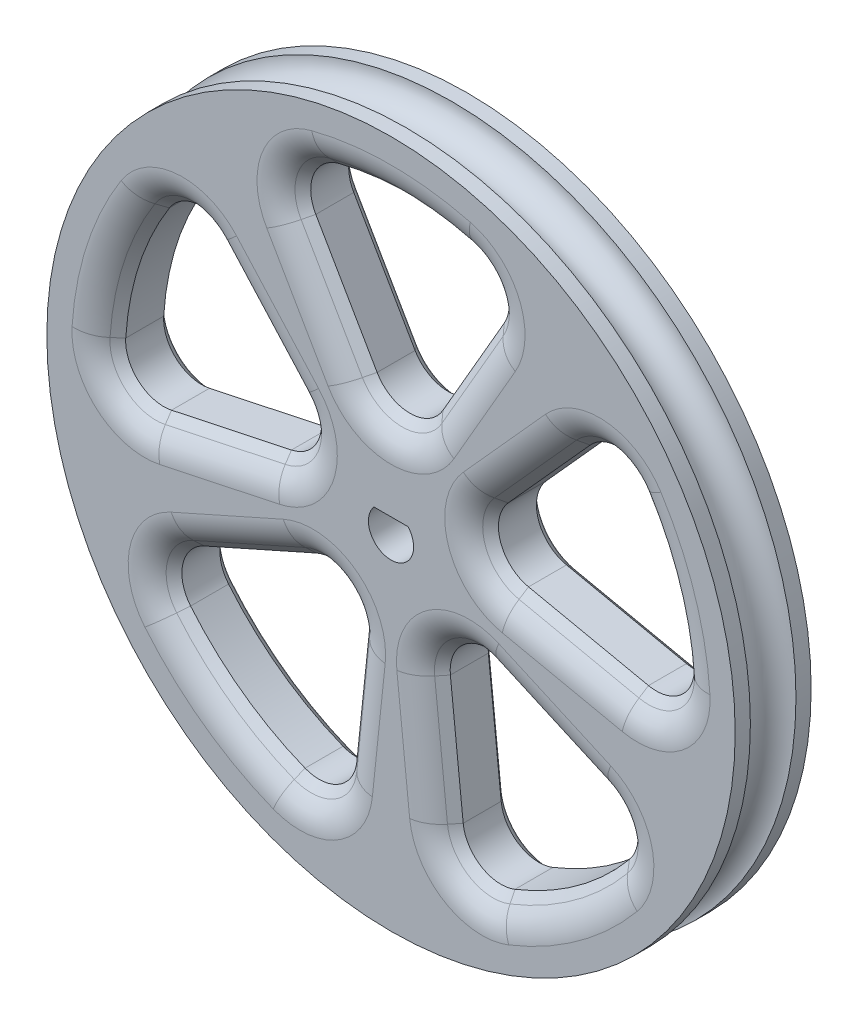
from build123d import *

# Parameters (mm, degrees)
SKETCH1_R                    = 23.01875
BOSS_EXTRUDE1_DEPTH          = 5.08
CUT_EXTRUDE3_DEPTH           = 5.08
FILLET3_R                    = 2.54
CHAMFER2_SIZE                = 1.27
CIRPATTERN3_COUNT            = 5
FILLET3_OF_CIRPATTERN3_R     = 2.54
CHAMFER2_OF_CIRPATTERN3_SIZE = 1.27
CUT_EXTRUDE4_DEPTH           = 5.08
FILLET4_R                    = 2.54


with BuildPart() as part:
    # Sketch1 → Boss-Extrude1 (new body)
    with BuildSketch(Plane.XY):
        Circle(SKETCH1_R)
    extrude(amount=BOSS_EXTRUDE1_DEPTH)

    # Sketch2 → Cut-Extrude3 (cut)
    with BuildSketch(Plane.XY.offset(5.08)):
        with BuildLine():
            Line((0, 3.81), (7.827476944, 17.367587762))
            ThreePointArc((7.827476944, 17.367587762), (0, 19.05), (-7.827476944, 17.367587762))
            Line((-7.827476944, 17.367587762), (0, 3.81))
        make_face()
    cut_extrude3 = extrude(amount=-CUT_EXTRUDE3_DEPTH, mode=Mode.SUBTRACT)

    # Fillet3
    fillet3_edges = [part.edges().sort_by_distance(p)[0] for p in [
        (7.827476944, 17.367587762, 2.54),
        (0, 3.81, 2.54),
        (-7.827476944, 17.367587762, 2.54),
    ]]
    fillet(fillet3_edges, radius=FILLET3_R)

    # Chamfer2
    chamfer2_edges = [part.edges().sort_by_distance(p)[0] for p in [
        (4.250057994, 11.17131638, 0),
        (4.250057994, 11.17131638, 5.08),
        (-4.250057994, 11.17131638, 5.08),
        (-4.250057994, 11.17131638, 0),
        (0, 19.05, 0),
        (0, 19.05, 5.08),
        (0, 6.35, 5.08),
        (0, 6.35, 0),
        (-6.442080419, 16.977300326, 5.08),
        (-6.442080419, 16.977300326, 0),
        (6.442080419, 16.977300326, 5.08),
        (6.442080419, 16.977300326, 0),
    ]]
    chamfer(chamfer2_edges, length=CHAMFER2_SIZE)

    # CirPattern3: Cut-Extrude3 ×5 about axis
    cirpattern3_axis = Axis((0, 0, 0), (0, 0, 1))
    for i in range(1, CIRPATTERN3_COUNT):
        add(cut_extrude3.rotate(cirpattern3_axis, i * 360 / CIRPATTERN3_COUNT), mode=Mode.SUBTRACT)

    # Fillet3 of CirPattern3
    fillet3_of_cirpattern3_edges = [part.edges().sort_by_distance(p)[0] for p in [
        (-14.098734115, 12.811252724, 2.54),
        (-3.623525327, 1.177354749, 2.54),
        (-18.936380913, -2.077493184, 2.54),
        (-16.540973826, -9.449798141, 2.54),
        (-2.239461811, -3.082354749, 2.54),
        (-3.875850084, -18.651549162, 2.54),
        (3.875850084, -18.651549162, 2.54),
        (2.239461811, -3.082354749, 2.54),
        (16.540973826, -9.449798141, 2.54),
        (18.936380913, -2.077493184, 2.54),
        (3.623525327, 1.177354749, 2.54),
        (14.098734115, 12.811252724, 2.54),
    ]]
    fillet(fillet3_of_cirpattern3_edges, radius=FILLET3_OF_CIRPATTERN3_R)

    # Chamfer2 of CirPattern3
    chamfer2_of_cirpattern3_edges = [part.edges().sort_by_distance(p)[0] for p in [
        (-9.311213092, 7.494171961, 0),
        (-9.311213092, 7.494171961, 5.08),
        (-11.937893386, -0.589918739, 5.08),
        (-11.937893386, -0.589918739, 0),
        (-18.117626635, 5.886773743, 0),
        (-18.117626635, 5.886773743, 5.08),
        (-6.039208878, 1.962257914, 5.08),
        (-6.039208878, 1.962257914, 0),
        (-18.137084433, -0.880508242, 5.08),
        (-18.137084433, -0.880508242, 0),
        (-14.155659776, 11.373056881, 5.08),
        (-14.155659776, 11.373056881, 0),
        (-10.004704161, -6.539663391, 0),
        (-10.004704161, -6.539663391, 5.08),
        (-3.127965873, -11.535906211, 5.08),
        (-3.127965873, -11.535906211, 0),
        (-11.197309056, -15.411773743, 0),
        (-11.197309056, -15.411773743, 5.08),
        (-3.732436352, -5.137257914, 5.08),
        (-3.732436352, -5.137257914, 0),
        (-4.767254217, -17.521484347, 5.08),
        (-4.767254217, -17.521484347, 0),
        (-15.190759294, -9.948364618, 5.08),
        (-15.190759294, -9.948364618, 0),
        (3.127965873, -11.535906211, 0),
        (3.127965873, -11.535906211, 5.08),
        (10.004704161, -6.539663391, 5.08),
        (10.004704161, -6.539663391, 0),
        (11.197309056, -15.411773743, 0),
        (11.197309056, -15.411773743, 5.08),
        (3.732436352, -5.137257914, 5.08),
        (3.732436352, -5.137257914, 0),
        (15.190759294, -9.948364618, 5.08),
        (15.190759294, -9.948364618, 0),
        (4.767254217, -17.521484347, 5.08),
        (4.767254217, -17.521484347, 0),
        (11.937893386, -0.589918739, 0),
        (11.937893386, -0.589918739, 5.08),
        (9.311213092, 7.494171961, 5.08),
        (9.311213092, 7.494171961, 0),
        (18.117626635, 5.886773743, 0),
        (18.117626635, 5.886773743, 5.08),
        (6.039208878, 1.962257914, 5.08),
        (6.039208878, 1.962257914, 0),
        (14.155659776, 11.373056881, 5.08),
        (14.155659776, 11.373056881, 0),
        (18.137084433, -0.880508242, 5.08),
        (18.137084433, -0.880508242, 0),
    ]]
    chamfer(chamfer2_of_cirpattern3_edges, length=CHAMFER2_OF_CIRPATTERN3_SIZE)

    # Sketch5 → Cut-Extrude4 (cut)
    with BuildSketch(Plane.XY.offset(5.08)):
        with BuildLine():
            ThreePointArc((1.141376069, 0.9906), (0, -1.5113), (-1.141376069, 0.9906))
            Line((-1.141376069, 0.9906), (1.141376069, 0.9906))
        make_face()
    extrude(amount=-CUT_EXTRUDE4_DEPTH, mode=Mode.SUBTRACT)

    # Fillet4
    fillet4_edges = [part.edges().sort_by_distance(p)[0] for p in [
        (-18.967083783, -1.84175799, 5.08),
        (-19.325468411, 6.279225326, 5.08),
        (-11.673845539, -1.832166191, 5.08),
        (-4.831367103, 1.569806331, 5.08),
        (-8.367419164, 8.343967831, 5.08),
        (-14.26213493, 12.63858564, 5.08),
        (-19.325468411, 6.279225326, 0),
        (-18.967083783, -1.84175799, 0),
        (-11.673845539, -1.832166191, 0),
        (-4.831367103, 1.569806331, 0),
        (-8.367419164, 8.343967831, 0),
        (-14.26213493, 12.63858564, 0),
        (-4.109535285, -18.607903146, 5.08),
        (-11.943796327, -16.439225326, 5.08),
        (-1.864923066, -11.66865736, 5.08),
        (-2.985949082, -4.109806331, 5.08),
        (-10.521259698, -5.37946066, 5.08),
        (-16.427251299, -9.658558614, 5.08),
        (-11.943796327, -16.439225326, 0),
        (-4.109535285, -18.607903146, 0),
        (-1.864923066, -11.66865736, 0),
        (-2.985949082, -4.109806331, 0),
        (-10.521259698, -5.37946066, 0),
        (-16.427251299, -9.658558614, 0),
        (16.427251299, -9.658558614, 5.08),
        (11.943796327, -16.439225326, 5.08),
        (10.521259698, -5.37946066, 5.08),
        (2.985949082, -4.109806331, 5.08),
        (1.864923066, -11.66865736, 5.08),
        (4.109535285, -18.607903146, 5.08),
        (11.943796327, -16.439225326, 0),
        (16.427251299, -9.658558614, 0),
        (10.521259698, -5.37946066, 0),
        (2.985949082, -4.109806331, 0),
        (1.864923066, -11.66865736, 0),
        (4.109535285, -18.607903146, 0),
        (14.26213493, 12.63858564, 5.08),
        (19.325468411, 6.279225326, 5.08),
        (8.367419164, 8.343967831, 5.08),
        (4.831367103, 1.569806331, 5.08),
        (11.673845539, -1.832166191, 5.08),
        (18.967083783, -1.84175799, 5.08),
        (19.325468411, 6.279225326, 0),
        (14.26213493, 12.63858564, 0),
        (8.367419164, 8.343967831, 0),
        (4.831367103, 1.569806331, 0),
        (11.673845539, -1.832166191, 0),
        (18.967083783, -1.84175799, 0),
        (-7.61276716, 17.469634109, 5.08),
        (0, 20.32, 5.08),
        (-5.349910257, 10.53631638, 5.08),
        (0, 5.08, 5.08),
        (5.349910257, 10.53631638, 5.08),
        (7.61276716, 17.469634109, 5.08),
        (0, 20.32, 0),
        (-7.61276716, 17.469634109, 0),
        (-5.349910257, 10.53631638, 0),
        (0, 5.08, 0),
        (5.349910257, 10.53631638, 0),
        (7.61276716, 17.469634109, 0),
    ]]
    fillet(fillet4_edges, radius=FILLET4_R)

    # Sketch7 → Cut-Revolve1 (revolve, cut)
    with BuildSketch(Plane(origin=(0, 0, 0), x_dir=(1, 0, 0), z_dir=(0, 1, 0))):
        with BuildLine():
            Line((-23.01875, -4.064), (-23.01875, -1.016))
            ThreePointArc((-23.01875, -1.016), (-21.49475, -2.54), (-23.01875, -4.064))
        make_face()
    revolve(axis=Axis((0, 0, 0), (0, 0, -1)), mode=Mode.SUBTRACT)


solid = part.part
